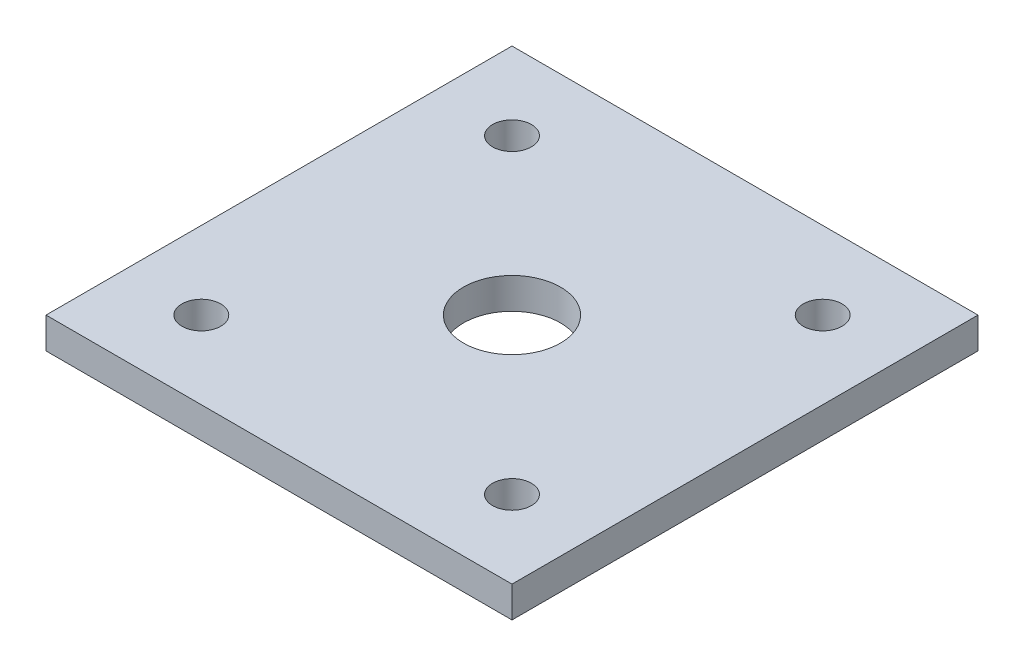
from build123d import *

# Parameters (mm, degrees)
BOSS_EXTRUDE2_DEPTH     = 8
SKETCH3_R               = 12.5
CUT_EXTRUDE1_DEPTH      = 9
SKETCH4_R               = 5
CUT_EXTRUDE2_DEPTH      = 9
MIRROR2_COPY_1_SKETCH_R = 5
MIRROR2_COPY_1_DEPTH    = 9


with BuildPart() as part:
    # Sketch1 → Boss-Extrude2 (new body)
    with BuildSketch(Plane(origin=(0, 0, 0), x_dir=(1, 0, 0), z_dir=(0, 1, 0))):
        Polygon((60, 60), (-60, 60), (0, 0), align=None)
        Polygon((0, 0), (-60, 60), (-60, -60), align=None)
        Polygon((60, -60), (0, 0), (-60, -60), align=None)
        Polygon((60, 60), (0, 0), (60, -60), align=None)
    extrude(amount=BOSS_EXTRUDE2_DEPTH)

    # Sketch3 → Cut-Extrude1 (cut, through all)
    with BuildSketch(Plane(origin=(0, 8, 0), x_dir=(1, 0, 0), z_dir=(0, 1, 0))):
        Circle(SKETCH3_R)
    extrude(amount=-CUT_EXTRUDE1_DEPTH, mode=Mode.SUBTRACT)

    # Sketch4 → Cut-Extrude2 (cut, through all)
    with BuildSketch(Plane(origin=(0, 8, 0), x_dir=(1, 0, 0), z_dir=(0, 1, 0))):
        with Locations((-40, 40)):
            Circle(SKETCH4_R)
    cut_extrude2 = extrude(amount=-CUT_EXTRUDE2_DEPTH, mode=Mode.SUBTRACT)

    # Mirror1: Cut-Extrude2 across plane
    add(cut_extrude2.mirror(Plane(origin=(0, 0, 0), x_dir=(0, 0, 1), z_dir=(1, 0, 0))), mode=Mode.SUBTRACT)

    # Mirror2: Cut-Extrude2 across plane
    add(cut_extrude2.mirror(Plane.XY), mode=Mode.SUBTRACT)

    # Mirror2 copy 1 sketch → Mirror2 copy 1 (cut, through all)
    with BuildSketch(Plane(origin=(0, 8, 0), x_dir=(-1, 0, 0), z_dir=(0, 1, 0))):
        with Locations((-40, 40)):
            Circle(MIRROR2_COPY_1_SKETCH_R)
    extrude(amount=-MIRROR2_COPY_1_DEPTH, mode=Mode.SUBTRACT)


solid = part.part
